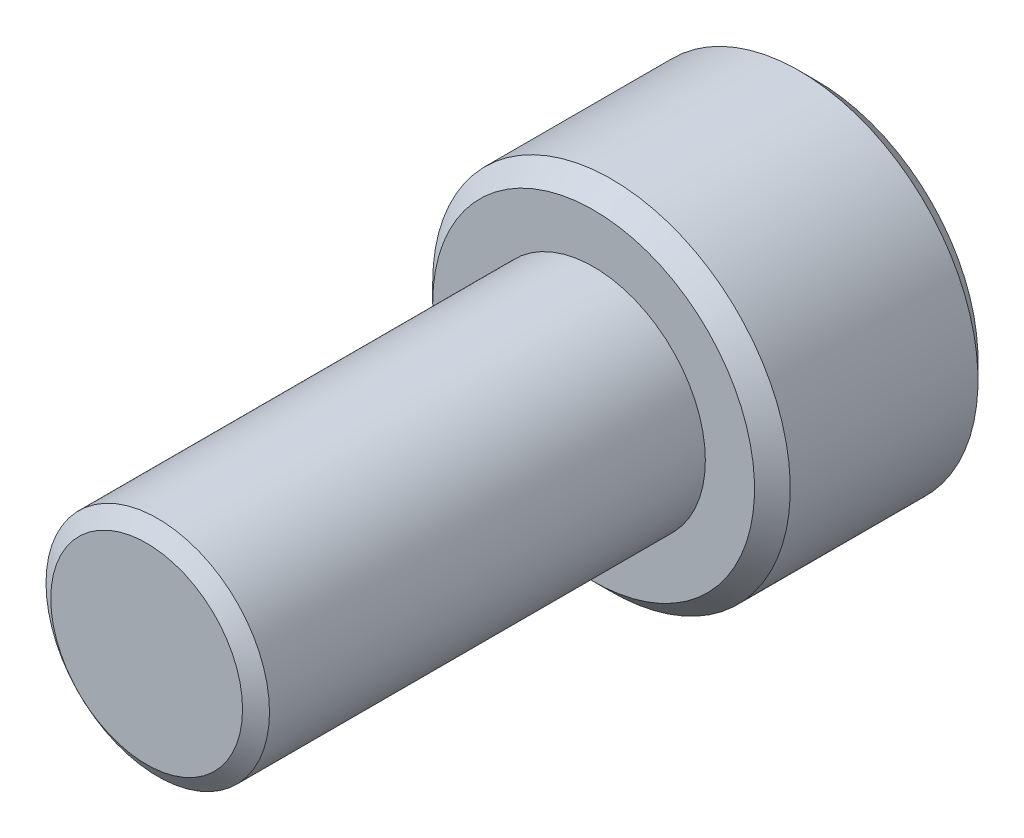
from build123d import *

# Parameters (mm, degrees)
SKETCH1_R          = 5
EXTRUDE1_DEPTH     = 20
SKETCH6_R          = 8
EXTRUDE2_DEPTH     = 10
CUT_EXTRUDE1_DEPTH = 6
CHAMFER1_SIZE      = 0.8


with BuildPart() as part:
    # Sketch1 → Extrude1 (new body)
    with BuildSketch(Plane.XY):
        Circle(SKETCH1_R)
    extrude(amount=-EXTRUDE1_DEPTH)

    # Sketch4 → Cut-Revolve1 (revolve, cut)
    with BuildSketch(Plane(origin=(0, 0, 0), x_dir=(0, 0, -1), z_dir=(1, 0, 0))):
        Polygon((0.496211411, 5), (0, 4.291336663), (0, 5), align=None)
    revolve(axis=Axis((0, 0, 0), (0, 0, -1)), mode=Mode.SUBTRACT)

    # Sketch6 → Extrude2 (add)
    with BuildSketch(Plane(origin=(0, 0, -20), x_dir=(-1, 0, 0), z_dir=(0, 0, -1))):
        Circle(SKETCH6_R)
    extrude(amount=EXTRUDE2_DEPTH)

    # Sketch7 → Cut-Extrude1 (cut)
    with BuildSketch(Plane(origin=(0, 0, -30), x_dir=(-1, 0, 0), z_dir=(0, 0, -1))):
        Polygon((0, 4.618802154), (-4, 2.309401077), (-4, -2.309401077), (0, -4.618802154), (4, -2.309401077), (4, 2.309401077), align=None)
    extrude(amount=-CUT_EXTRUDE1_DEPTH, mode=Mode.SUBTRACT)

    # Cut-Extrude2 cone 1 section (through the dimple's axis) → Cut-Extrude2 (revolve, cut)
    with BuildSketch(Plane(origin=(0, 0, -30), x_dir=(0, 1, 0), z_dir=(1, 0, 0))):
        Polygon((0, 0), (4.618802154, 0), (0, 4.618802154), align=None)
    revolve(axis=Axis((0, 0, -30), (0, 0, 1)), mode=Mode.SUBTRACT)

    # Chamfer1
    chamfer1_edges = [part.edges().sort_by_distance(p)[0] for p in [
        (8, 0, -30),
        (8, 0, -20),
    ]]
    chamfer(chamfer1_edges, length=CHAMFER1_SIZE)


solid = part.part
